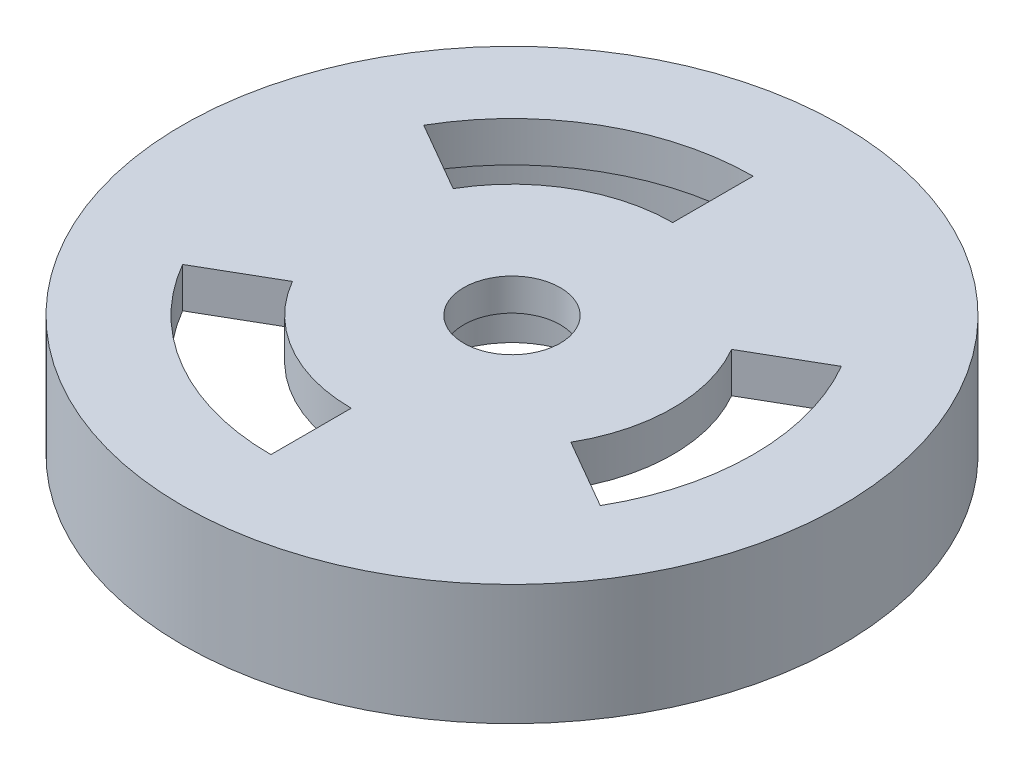
from build123d import *

# Parameters (mm, degrees)
SKETCH1_R           = 41
SKETCH1_R_2         = 38
BOSS_EXTRUDE1_DEPTH = 10
SKETCH3_R           = 41
BOSS_EXTRUDE2_DEPTH = 5
SKETCH4_R           = 12.5
BOSS_EXTRUDE3_DEPTH = 5
SKETCH5_R           = 10
CUT_EXTRUDE1_DEPTH  = 6
SKETCH6_R           = 6
CUT_EXTRUDE2_DEPTH  = 5
CUT_EXTRUDE3_DEPTH  = 6


with BuildPart() as part:
    # Sketch1 → Boss-Extrude1 (new body)
    with BuildSketch(Plane(origin=(0, 0, 0), x_dir=(1, 0, 0), z_dir=(0, 1, 0))):
        Circle(SKETCH1_R)
        Circle(SKETCH1_R_2, mode=Mode.SUBTRACT)
    extrude(amount=BOSS_EXTRUDE1_DEPTH)

    # Sketch3 → Boss-Extrude2 (add)
    with BuildSketch(Plane(origin=(0, 10, 0), x_dir=(1, 0, 0), z_dir=(0, 1, 0))):
        Circle(SKETCH3_R)
    extrude(amount=BOSS_EXTRUDE2_DEPTH)

    # Sketch4 → Boss-Extrude3 (add)
    with BuildSketch(Plane.XZ.offset(-10)):
        Circle(SKETCH4_R)
    extrude(amount=BOSS_EXTRUDE3_DEPTH)

    # Sketch5 → Cut-Extrude1 (cut)
    with BuildSketch(Plane.XZ.offset(-5)):
        Circle(SKETCH5_R)
    extrude(amount=-CUT_EXTRUDE1_DEPTH, mode=Mode.SUBTRACT)

    # Sketch6 → Cut-Extrude2 (cut, through all)
    with BuildSketch(Plane.XZ.offset(-11)):
        Circle(SKETCH6_R)
    extrude(amount=-CUT_EXTRUDE2_DEPTH, mode=Mode.SUBTRACT)

    # Sketch7 → Cut-Extrude3 (cut, through all)
    with BuildSketch(Plane.XZ.offset(-10)):
        with BuildLine():
            Line((0, 20), (0, 30))
            ThreePointArc((0, 30), (-15, 25.980762114), (-25.980762114, 15))
            Line((-25.980762114, 15), (-17.320508076, 10))
            ThreePointArc((-17.320508076, 10), (-10, 17.320508076), (0, 20))
        make_face()
        with BuildLine():
            Line((17.320508076, -10), (25.980762114, -15))
            ThreePointArc((25.980762114, -15), (30, 0), (25.980762114, 15))
            Line((25.980762114, 15), (17.320508076, 10))
            ThreePointArc((17.320508076, 10), (20, 0), (17.320508076, -10))
        make_face()
        with BuildLine():
            Line((-17.320508076, -10), (-25.980762114, -15))
            ThreePointArc((-25.980762114, -15), (-15, -25.980762114), (0, -30))
            Line((0, -30), (0, -20))
            ThreePointArc((0, -20), (-10, -17.320508076), (-17.320508076, -10))
        make_face()
    extrude(amount=-CUT_EXTRUDE3_DEPTH, mode=Mode.SUBTRACT)


solid = part.part
